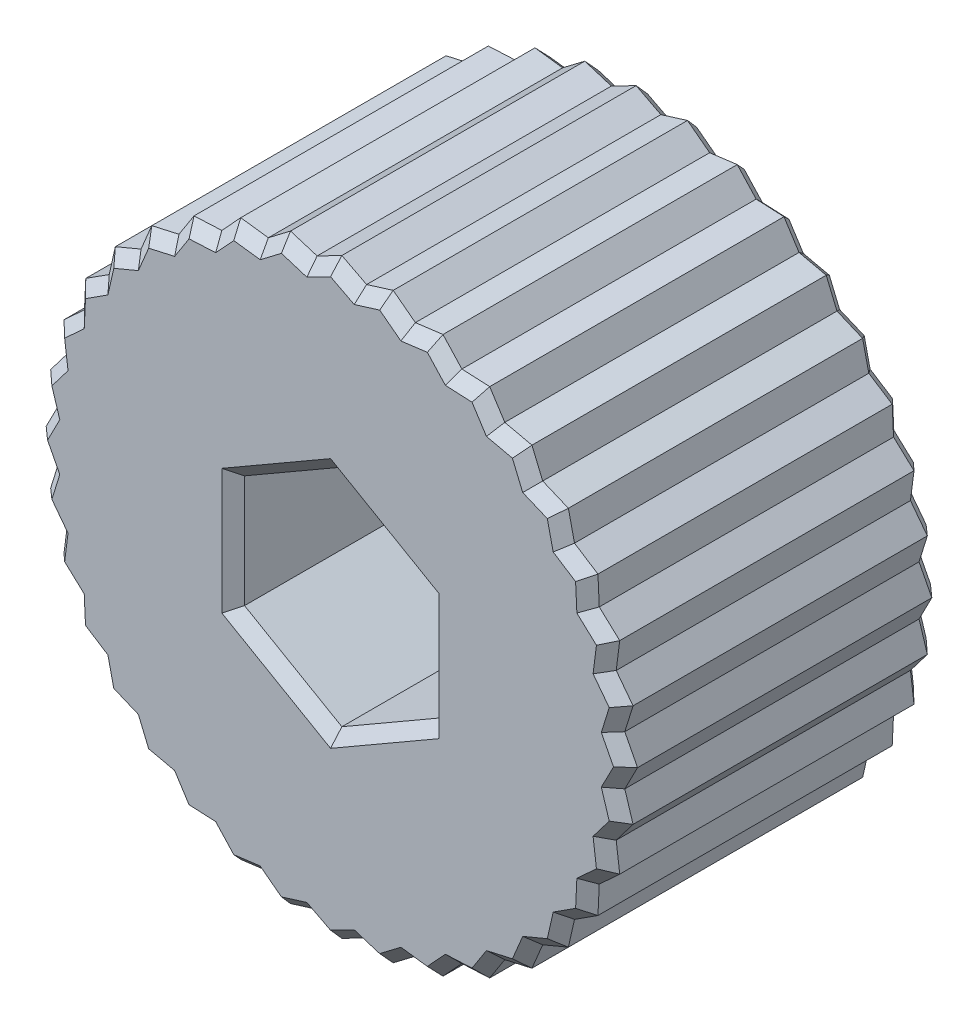
from build123d import *

# Parameters (mm, degrees)
SKETCH1_R           = 12.5
BOSS_EXTRUDE1_DEPTH = 14
SKETCH3_R           = 5.801475605
SKETCH3_R_2         = 2.9
BOSS_EXTRUDE3_DEPTH = 2
CUT_EXTRUDE1_DEPTH  = 7.5
SKETCH5_R           = 12.090152216
BOSS_EXTRUDE4_DEPTH = 14
CHAMFER2_SIZE       = 0.5


with BuildPart() as part:
    # Sketch1 → Boss-Extrude1 (new body)
    with BuildSketch(Plane.XY):
        Circle(SKETCH1_R)
        Polygon((0, 4.67653718), (-4.05, 2.33826859), (-4.05, -2.33826859), (0, -4.67653718), (4.05, -2.33826859), (4.05, 2.33826859), align=None, mode=Mode.SUBTRACT)
    extrude(amount=BOSS_EXTRUDE1_DEPTH)

    # Sketch3 → Boss-Extrude3 (add)
    with BuildSketch(Plane(origin=(0, 0, 0), x_dir=(-1, 0, 0), z_dir=(0, 0, -1))):
        Circle(SKETCH3_R)
        Circle(SKETCH3_R_2, mode=Mode.SUBTRACT)
    extrude(amount=-BOSS_EXTRUDE3_DEPTH)

    # Sketch4 → Cut-Extrude1 (cut)
    with BuildSketch(Plane.XY.offset(14)):
        Polygon((0, 4.965212315), (-4.3, 2.482606158), (-4.3, -2.482606158), (0, -4.965212315), (4.3, -2.482606158), (4.3, 2.482606158), align=None)
    extrude(amount=-CUT_EXTRUDE1_DEPTH, mode=Mode.SUBTRACT)

    # Sketch5 → Boss-Extrude4 (add)
    with BuildSketch(Plane.XY.offset(14)):
        Polygon((0, 13.063196798), (1.093562728, 12.499479176), (2.268400319, 12.864737486), (3.247460833, 12.119688826), (4.467876441, 12.275389635), (5.302686485, 11.371647864), (6.531598399, 11.313060282), (7.196792691, 10.278085136), (8.396861045, 10.006989317), (8.872227993, 8.872227993), (10.006989317, 8.396861045), (10.278085136, 7.196792691), (11.313060282, 6.531598399), (11.371647864, 5.302686485), (12.275389635, 4.467876441), (12.119688826, 3.247460833), (12.864737486, 2.268400319), (12.499479176, 1.093562728), (13.063196798, 0), (12.499479176, -1.093562728), (12.864737486, -2.268400319), (12.119688826, -3.247460833), (12.275389635, -4.467876441), (11.371647864, -5.302686485), (11.313060282, -6.531598399), (10.278085136, -7.196792691), (10.006989317, -8.396861045), (8.872227993, -8.872227993), (8.396861045, -10.006989317), (7.196792691, -10.278085136), (6.531598399, -11.313060282), (5.302686485, -11.371647864), (4.467876441, -12.275389635), (3.247460833, -12.119688826), (2.268400319, -12.864737486), (1.093562728, -12.499479176), (0, -13.063196798), (-1.093562728, -12.499479176), (-2.268400319, -12.864737486), (-3.247460833, -12.119688826), (-4.467876441, -12.275389635), (-5.302686485, -11.371647864), (-6.531598399, -11.313060282), (-7.196792691, -10.278085136), (-8.396861045, -10.006989317), (-8.872227993, -8.872227993), (-10.006989317, -8.396861045), (-10.278085136, -7.196792691), (-11.313060282, -6.531598399), (-11.371647864, -5.302686485), (-12.275389635, -4.467876441), (-12.119688826, -3.247460833), (-12.864737486, -2.268400319), (-12.499479176, -1.093562728), (-13.063196798, 0), (-12.499479176, 1.093562728), (-12.864737486, 2.268400319), (-12.119688826, 3.247460833), (-12.275389635, 4.467876441), (-11.371647864, 5.302686485), (-11.313060282, 6.531598399), (-10.278085136, 7.196792691), (-10.006989317, 8.396861045), (-8.872227993, 8.872227993), (-8.396861045, 10.006989317), (-7.196792691, 10.278085136), (-6.531598399, 11.313060282), (-5.302686485, 11.371647864), (-4.467876441, 12.275389635), (-3.247460833, 12.119688826), (-2.268400319, 12.864737486), (-1.093562728, 12.499479176), align=None)
        Circle(SKETCH5_R, mode=Mode.SUBTRACT)
    extrude(amount=-BOSS_EXTRUDE4_DEPTH)

    # Chamfer2
    chamfer2_edges = [part.edges().sort_by_distance(p)[0] for p in [
        (12.492213156, -2.757930576, 14),
        (12.682108331, -1.680981523, 14),
        (12.781337987, -0.546781364, 14),
        (12.781337987, 0.546781364, 14),
        (12.682108331, 1.680981523, 14),
        (12.492213156, 2.757930576, 14),
        (12.197539231, 3.857668637, 14),
        (11.82351875, 4.885281463, 14),
        (11.342354073, 5.917142442, 14),
        (10.795572709, 6.864195545, 14),
        (10.142537226, 7.796826868, 14),
        (9.439608655, 8.634544519, 14),
        (8.634544519, 9.439608655, 14),
        (7.796826868, 10.142537226, 14),
        (6.864195545, 10.795572709, 14),
        (5.917142442, 11.342354073, 14),
        (4.885281463, 11.82351875, 14),
        (3.857668637, 12.197539231, 14),
        (2.757930576, 12.492213156, 14),
        (1.680981523, 12.682108331, 14),
        (0.546781364, 12.781337987, 14),
        (-0.546781364, 12.781337987, 0),
        (0.546781364, 12.781337987, 0),
        (1.680981523, 12.682108331, 0),
        (2.757930576, 12.492213156, 0),
        (3.857668637, 12.197539231, 0),
        (4.885281463, 11.82351875, 0),
        (5.917142442, 11.342354073, 0),
        (6.864195545, 10.795572709, 0),
        (7.796826868, 10.142537226, 0),
        (8.634544519, 9.439608655, 0),
        (9.439608655, 8.634544519, 0),
        (10.142537226, 7.796826868, 0),
        (10.795572709, 6.864195545, 0),
        (11.342354073, 5.917142442, 0),
        (11.82351875, 4.885281463, 0),
        (12.197539231, 3.857668637, 0),
        (12.492213156, 2.757930576, 0),
        (12.682108331, 1.680981523, 0),
        (12.781337987, 0.546781364, 0),
        (12.781337987, -0.546781364, 0),
        (12.682108331, -1.680981523, 0),
        (12.492213156, -2.757930576, 0),
        (12.197539231, -3.857668637, 0),
        (11.82351875, -4.885281463, 0),
        (11.342354073, -5.917142442, 0),
        (10.795572709, -6.864195545, 0),
        (10.142537226, -7.796826868, 0),
        (9.439608655, -8.634544519, 0),
        (8.634544519, -9.439608655, 0),
        (7.796826868, -10.142537226, 0),
        (6.864195545, -10.795572709, 0),
        (5.917142442, -11.342354073, 0),
        (4.885281463, -11.82351875, 0),
        (3.857668637, -12.197539231, 0),
        (2.757930576, -12.492213156, 0),
        (1.680981523, -12.682108331, 0),
        (0.546781364, -12.781337987, 0),
        (-0.546781364, -12.781337987, 0),
        (-1.680981523, -12.682108331, 0),
        (-2.757930576, -12.492213156, 0),
        (-3.857668637, -12.197539231, 0),
        (-4.885281463, -11.82351875, 0),
        (-5.917142442, -11.342354073, 0),
        (-6.864195545, -10.795572709, 0),
        (-7.796826868, -10.142537226, 0),
        (-8.634544519, -9.439608655, 0),
        (-9.439608655, -8.634544519, 0),
        (-10.142537226, -7.796826868, 0),
        (-10.795572709, -6.864195545, 0),
        (-11.342354073, -5.917142442, 0),
        (-11.82351875, -4.885281463, 0),
        (-12.197539231, -3.857668637, 0),
        (-12.492213156, -2.757930576, 0),
        (-12.682108331, -1.680981523, 0),
        (-12.781337987, -0.546781364, 0),
        (-12.781337987, 0.546781364, 0),
        (-12.682108331, 1.680981523, 0),
        (-12.492213156, 2.757930576, 0),
        (-12.197539231, 3.857668637, 0),
        (-11.82351875, 4.885281463, 0),
        (-11.342354073, 5.917142442, 0),
        (-10.795572709, 6.864195545, 0),
        (-10.142537226, 7.796826868, 0),
        (-9.439608655, 8.634544519, 0),
        (-8.634544519, 9.439608655, 0),
        (-7.796826868, 10.142537226, 0),
        (-6.864195545, 10.795572709, 0),
        (-5.917142442, 11.342354073, 0),
        (-4.885281463, 11.82351875, 0),
        (-3.857668637, 12.197539231, 0),
        (-2.757930576, 12.492213156, 0),
        (-1.680981523, 12.682108331, 0),
        (2.9, 0, 0),
        (2.15, 3.723909236, 14),
        (-2.15, 3.723909236, 14),
        (-4.3, 0, 14),
        (-2.15, -3.723909236, 14),
        (2.15, -3.723909236, 14),
        (4.3, 0, 14),
        (-0.546781364, 12.781337987, 14),
        (-1.680981523, 12.682108331, 14),
        (-2.757930576, 12.492213156, 14),
        (-3.857668637, 12.197539231, 14),
        (-4.885281463, 11.82351875, 14),
        (-5.917142442, 11.342354073, 14),
        (-6.864195545, 10.795572709, 14),
        (-7.796826868, 10.142537226, 14),
        (-8.634544519, 9.439608655, 14),
        (-9.439608655, 8.634544519, 14),
        (-10.142537226, 7.796826868, 14),
        (-10.795572709, 6.864195545, 14),
        (-11.342354073, 5.917142442, 14),
        (-11.82351875, 4.885281463, 14),
        (-12.197539231, 3.857668637, 14),
        (-12.492213156, 2.757930576, 14),
        (-12.682108331, 1.680981523, 14),
        (-12.781337987, 0.546781364, 14),
        (-12.781337987, -0.546781364, 14),
        (-12.682108331, -1.680981523, 14),
        (-12.492213156, -2.757930576, 14),
        (-12.197539231, -3.857668637, 14),
        (-11.82351875, -4.885281463, 14),
        (-11.342354073, -5.917142442, 14),
        (-10.795572709, -6.864195545, 14),
        (-10.142537226, -7.796826868, 14),
        (-9.439608655, -8.634544519, 14),
        (-8.634544519, -9.439608655, 14),
        (-7.796826868, -10.142537226, 14),
        (-6.864195545, -10.795572709, 14),
        (-5.917142442, -11.342354073, 14),
        (-4.885281463, -11.82351875, 14),
        (-3.857668637, -12.197539231, 14),
        (-2.757930576, -12.492213156, 14),
        (-1.680981523, -12.682108331, 14),
        (-0.546781364, -12.781337987, 14),
        (0.546781364, -12.781337987, 14),
        (1.680981523, -12.682108331, 14),
        (2.757930576, -12.492213156, 14),
        (3.857668637, -12.197539231, 14),
        (4.885281463, -11.82351875, 14),
        (5.917142442, -11.342354073, 14),
        (6.864195545, -10.795572709, 14),
        (7.796826868, -10.142537226, 14),
        (8.634544519, -9.439608655, 14),
        (9.439608655, -8.634544519, 14),
        (10.142537226, -7.796826868, 14),
        (10.795572709, -6.864195545, 14),
        (11.342354073, -5.917142442, 14),
        (11.82351875, -4.885281463, 14),
        (12.197539231, -3.857668637, 14),
    ]]
    chamfer(chamfer2_edges, length=CHAMFER2_SIZE)


solid = part.part
